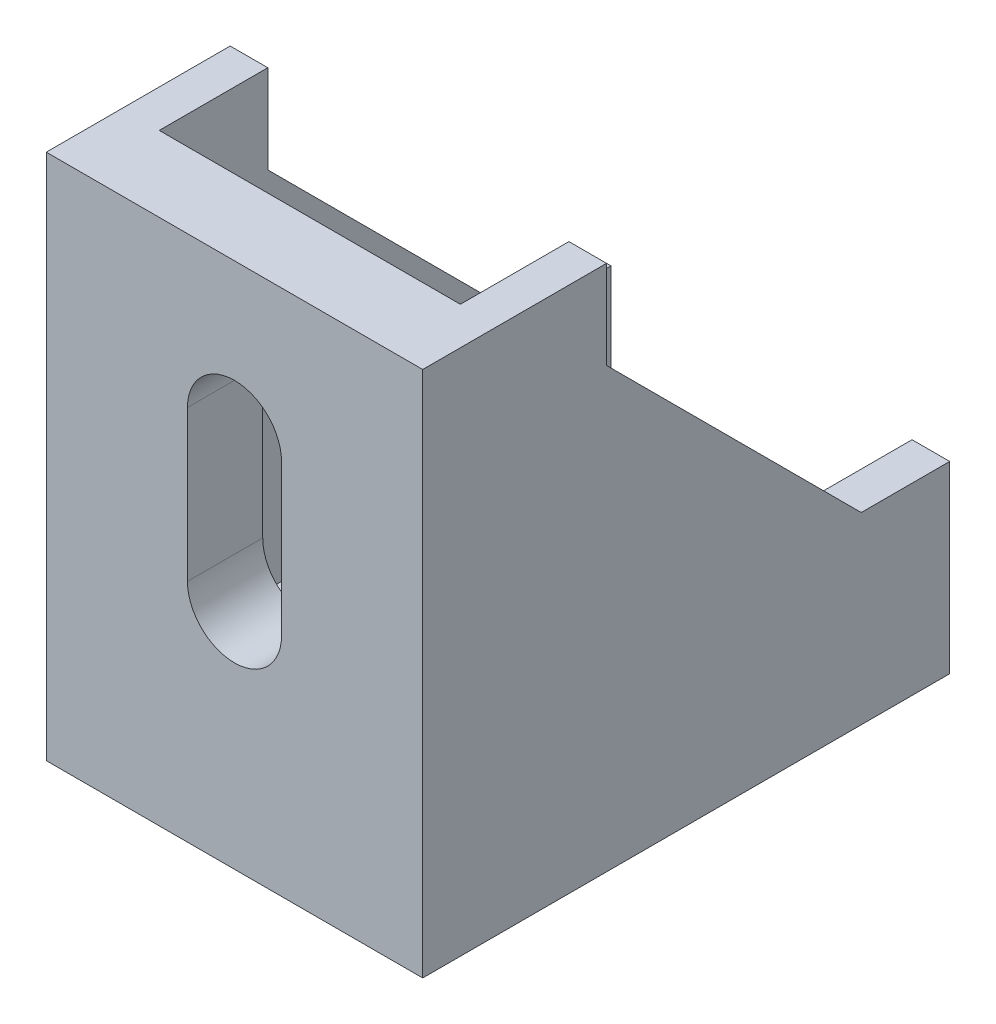
from build123d import *

# Parameters (mm, degrees)
BOSS_EXTRUDE2_DEPTH = 20
BOSS_EXTRUDE3_DEPTH = 2
BOSS_EXTRUDE4_START = 20
BOSS_EXTRUDE4_DEPTH = 2
CUT_EXTRUDE1_DEPTH  = 5
CUT_EXTRUDE2_DEPTH  = 5


with BuildPart() as part:
    # Sketch1 → Boss-Extrude2 (new body)
    with BuildSketch(Plane(origin=(0, 0, 0), x_dir=(0, 0, -1), z_dir=(1, 0, 0))):
        Polygon((0, 28), (0, 0), (28, 0), (28, 4), (4, 4), (4, 28), align=None)
    extrude(amount=BOSS_EXTRUDE2_DEPTH)

    # Sketch1_4 → Boss-Extrude3 (add)
    with BuildSketch(Plane(origin=(0, 0, 0), x_dir=(0, 0, -1), z_dir=(1, 0, 0))):
        Polygon((9.768810499, 28), (4, 28), (4, 4), (28, 4), (28, 9.768810499), (23.299944734, 9.768810499), (9.768810499, 23.299944734), align=None)
    extrude(amount=BOSS_EXTRUDE3_DEPTH)

    # Sketch1_5 → Boss-Extrude4 (add)
    with BuildSketch(Plane(origin=(0, 0, 0), x_dir=(0, 0, -1), z_dir=(1, 0, 0)).offset(BOSS_EXTRUDE4_START)):
        Polygon((9.768810499, 28), (4, 28), (4, 4), (28, 4), (28, 9.768810499), (23.299944734, 9.768810499), (9.768810499, 23.299944734), align=None)
    extrude(amount=-BOSS_EXTRUDE4_DEPTH)

    # Sketch2 → Cut-Extrude1 (cut, through all)
    with BuildSketch(Plane(origin=(0, 4, 0), x_dir=(1, 0, 0), z_dir=(0, 1, 0))):
        with BuildLine():
            Line((7.5, 12), (7.5, 20))
            ThreePointArc((7.5, 20), (10, 22.5), (12.5, 20))
            Line((12.5, 20), (12.5, 12))
            ThreePointArc((12.5, 12), (10, 9.5), (7.5, 12))
        make_face()
    extrude(amount=-CUT_EXTRUDE1_DEPTH, mode=Mode.SUBTRACT)

    # Sketch4 → Cut-Extrude2 (cut, through all)
    with BuildSketch(Plane(origin=(0, 0, -4), x_dir=(-1, 0, 0), z_dir=(0, 0, -1))):
        with BuildLine():
            Line((-12.5, 12), (-12.5, 20))
            ThreePointArc((-12.5, 20), (-10, 22.5), (-7.5, 20))
            Line((-7.5, 20), (-7.5, 12))
            ThreePointArc((-7.5, 12), (-10, 9.5), (-12.5, 12))
        make_face()
    extrude(amount=-CUT_EXTRUDE2_DEPTH, mode=Mode.SUBTRACT)


solid = part.part
